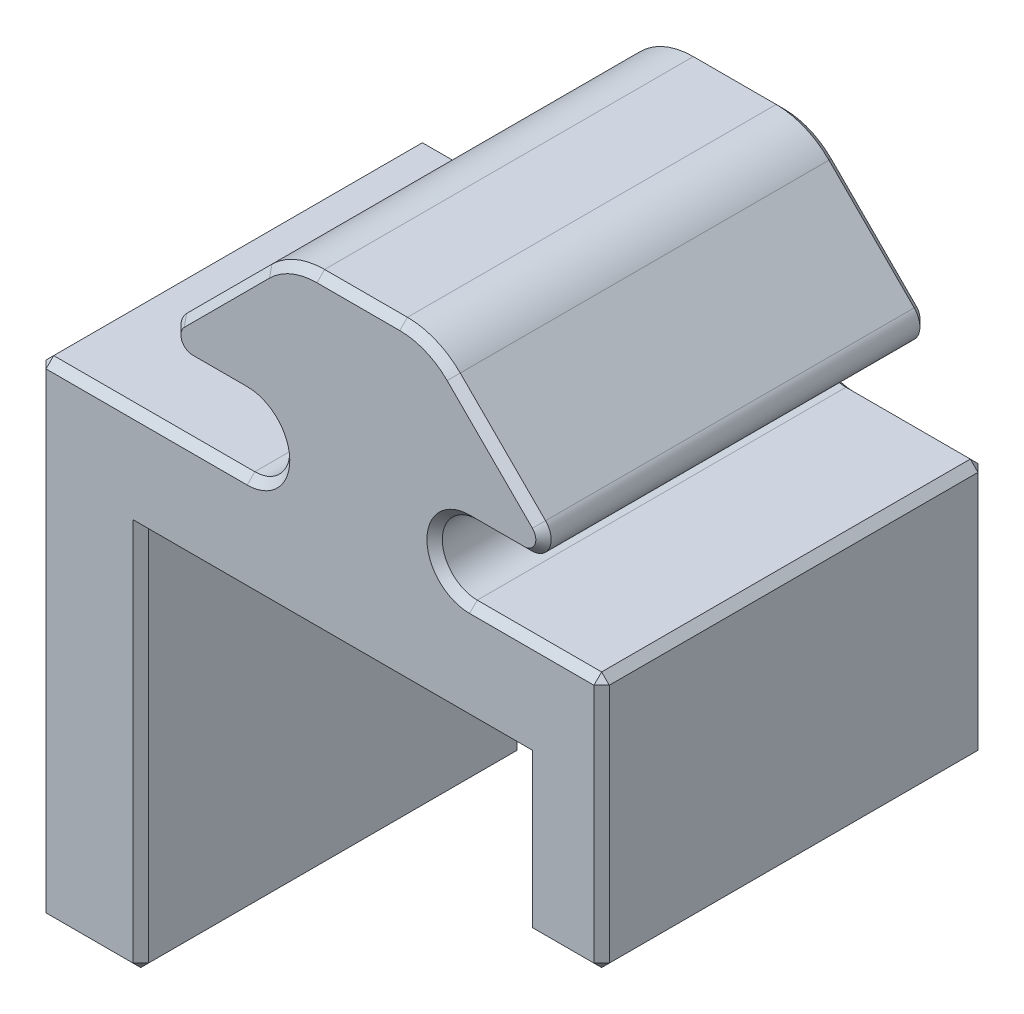
from build123d import *

# Parameters (mm, degrees)
BOSS_EXTRUDE1_DEPTH = 15
SKETCH2_W           = 4
SKETCH2_H           = 15
BOSS_EXTRUDE2_DEPTH = 15
SKETCH3_W           = 3
SKETCH3_H           = 15
BOSS_EXTRUDE3_DEPTH = 6
CHAMFER1_SIZE       = 0.3


with BuildPart() as part:
    # Sketch1 → Boss-Extrude1 (new body)
    with BuildSketch(Plane.XY):
        with BuildLine():
            Line((4.343399971, -3.3621), (5.0570836, -3.3621))
            Line((5.0570836, -3.3621), (9.5, -3.3621))
            Line((9.5, -3.3621), (9.5, -7.3621))
            Line((9.5, -7.3621), (-12.5, -7.3621))
            Line((-12.5, -7.3621), (-12.5, -3.3621))
            Line((-12.5, -3.3621), (-5.0570836, -3.3621))
            Line((-5.0570836, -3.3621), (-4.3434, -3.3621))
            ThreePointArc((-4.3434, -3.3621), (-2.9785, -1.9972), (-4.3434, -0.6323))
            Line((-4.3434, -0.6323), (-6.474794456, -0.6323))
            ThreePointArc((-6.474794456, -0.6323), (-7.173247382, -0.165608675), (-7.009367182, 0.658272727))
            Line((-7.009367182, 0.658272727), (-3.679323642, 3.988316267))
            ThreePointArc((-3.679323642, 3.988316267), (-2.73362958, 4.620208837), (-1.618107374, 4.8421))
            Line((-1.618107374, 4.8421), (1.618107374, 4.8421))
            ThreePointArc((1.618107374, 4.8421), (2.73362958, 4.620208837), (3.679323642, 3.988316267))
            Line((3.679323642, 3.988316267), (7.009367182, 0.658272727))
            ThreePointArc((7.009367182, 0.658272727), (7.173247382, -0.165608675), (6.474794456, -0.6323))
            Line((6.474794456, -0.6323), (4.343399971, -0.6323))
            ThreePointArc((4.343399971, -0.6323), (2.978499971, -1.9972), (4.343399971, -3.3621))
        make_face()
    extrude(amount=BOSS_EXTRUDE1_DEPTH)

    # Sketch2 → Boss-Extrude2 (add)
    with BuildSketch(Plane.XZ.offset(7.3621)):
        with Locations((-10.5, 7.5)):
            Rectangle(SKETCH2_W, SKETCH2_H)
    extrude(amount=BOSS_EXTRUDE2_DEPTH)

    # Sketch3 → Boss-Extrude3 (add)
    with BuildSketch(Plane.XZ.offset(7.3621)):
        with Locations((8, 7.5)):
            Rectangle(SKETCH3_W, SKETCH3_H)
    extrude(amount=BOSS_EXTRUDE3_DEPTH)

    # Chamfer1
    chamfer1_edges = [part.edges().sort_by_distance(p)[0] for p in [
        (9.5, -8.3621, 15),
        (-8.4217, -3.3621, 0),
        (-2.9785, -1.9972, 0),
        (-5.409097228, -0.6323, 0),
        (-7.173247382, -0.165608675, 0),
        (-5.344345412, 2.323294497, 0),
        (-2.73362958, 4.620208837, 0),
        (0, 4.8421, 0),
        (2.73362958, 4.620208837, 0),
        (5.344345412, 2.323294497, 0),
        (6.921699986, -3.3621, 15),
        (7.173247382, -0.165608675, 0),
        (5.409097213, -0.6323, 0),
        (2.978499971, -1.9972, 0),
        (6.921699986, -3.3621, 0),
        (9.5, -8.3621, 0),
        (-12.5, -12.8621, 0),
        (2.978499971, -1.9972, 15),
        (9.5, -3.3621, 7.5),
        (-12.5, -3.3621, 7.5),
        (5.409097213, -0.6323, 15),
        (7.173247382, -0.165608675, 15),
        (5.344345412, 2.323294497, 15),
        (2.73362958, 4.620208837, 15),
        (0, 4.8421, 15),
        (-8.4217, -3.3621, 15),
        (-1, -7.3621, 0),
        (-1, -7.3621, 15),
        (-2.73362958, 4.620208837, 15),
        (-8.5, -14.8621, 0),
        (-8.5, -14.8621, 15),
        (-12.5, -22.3621, 7.5),
        (-10.5, -22.3621, 0),
        (-8.5, -22.3621, 7.5),
        (-10.5, -22.3621, 15),
        (-5.344345412, 2.323294497, 15),
        (-7.173247382, -0.165608675, 15),
        (-5.409097228, -0.6323, 15),
        (6.5, -10.3621, 15),
        (6.5, -10.3621, 0),
        (9.5, -13.3621, 7.5),
        (8, -13.3621, 15),
        (6.5, -13.3621, 7.5),
        (8, -13.3621, 0),
        (-2.9785, -1.9972, 15),
        (-12.5, -12.8621, 15),
    ]]
    chamfer(chamfer1_edges, length=CHAMFER1_SIZE)


solid = part.part
